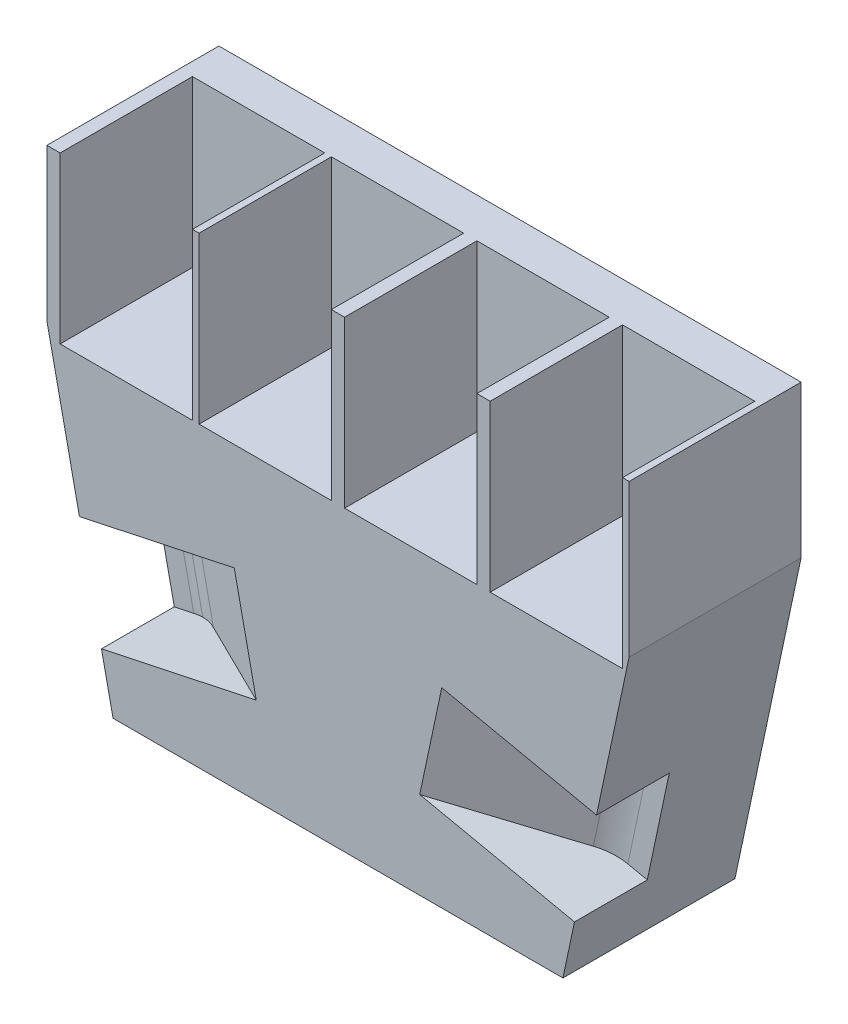
from build123d import *

# Parameters (mm, degrees)
EXTRUDE_1_DEPTH     = 26
SKETCH_3_W          = 40
SKETCH_3_H          = 36
CUT_EXTRUDE_4_DEPTH = 20
SKETCH_4_W          = 20
SKETCH_4_H          = 20
CUT_EXTRUDE_5_DEPTH = 25
CUT_EXTRUDE_3_DEPTH = 8
CUT_EXTRUDE_6_DEPTH = 8
CUT_EXTRUDE_7_DEPTH = 16
CUT_EXTRUDE_8_DEPTH = 16


with BuildPart() as part:
    # 草图1 → 凸台-拉伸1 (new body)
    with BuildSketch(Plane.XY):
        Polygon((-34, -24), (34, -24), (44, 23), (44, 46), (-44, 46), (-44, 23), align=None)
    extrude(amount=EXTRUDE_1_DEPTH)

    # 草图3 → 切除-拉伸4 (cut)
    with BuildSketch(Plane(origin=(0, 0, 0), x_dir=(-1, 0, 0), z_dir=(0, 0, -1))):
        with Locations((0, -6)):
            Rectangle(SKETCH_3_W, SKETCH_3_H)
    extrude(amount=-CUT_EXTRUDE_4_DEPTH, mode=Mode.SUBTRACT)

    # 草图4 → 切除-拉伸5 (cut)
    with BuildSketch(Plane(origin=(0, 46, 0), x_dir=(1, 0, 0), z_dir=(0, 1, 0))):
        with Locations((33, -16)):
            Rectangle(SKETCH_4_W, SKETCH_4_H)
        with Locations((11, -16)):
            Rectangle(SKETCH_4_W, SKETCH_4_H)
        with Locations((-11, -16)):
            Rectangle(SKETCH_4_W, SKETCH_4_H)
        with Locations((-32, -16)):
            Rectangle(SKETCH_4_W, SKETCH_4_H)
    extrude(amount=-CUT_EXTRUDE_5_DEPTH, mode=Mode.SUBTRACT)

    # Sketch 3D_5 → 切除-拉伸3 (cut, symmetric)
    with BuildSketch(Plane(origin=(-26.633413551, -5.666683734, 23.004025099), x_dir=(-0.691625335103945, -0.14715432661786076, 0.7071067811865475), z_dir=(-0.2081076444648591, 0.9781059289848354, 0))):
        with BuildLine():
            Line((0, 0), (5.656854249, 5.656854249))
            Line((5.656854249, 5.656854249), (11.313708499, 0))
            ThreePointArc((11.313708499, 0), (5.656854249, -13.656854249), (0, 0))
        make_face()
    extrude(amount=CUT_EXTRUDE_3_DEPTH, both=True, mode=Mode.SUBTRACT)

    # Sketch 3D_6 → 切除-拉伸6 (cut, symmetric)
    with BuildSketch(Plane(origin=(34.478414998, -7.335832978, 14.99907516), x_dir=(0.5895982688198705, -0.12544644017993214, 0.7978954016979886), z_dir=(-0.20810764446495697, -0.9781059289848145, -6.6559639472978385e-12))):
        with BuildLine():
            Line((0, 0), (6.376045072, -8.439700449))
            Line((6.376045072, -8.439700449), (17.547318622, 0))
            Line((17.547318622, 0), (11.17127355, 8.439700449))
            Line((11.17127355, 8.439700449), (6.348906145, 14.822863662))
            Line((6.348906145, 14.822863662), (1.560795809, 11.205530619))
            ThreePointArc((1.560795809, 11.205530619), (-1.540343474, 5.926016705), (0, 0))
        make_face()
    extrude(amount=CUT_EXTRUDE_6_DEPTH, both=True, mode=Mode.SUBTRACT)

    # 草图7 → 切除-拉伸7 (cut)
    with BuildSketch(Plane(origin=(-1.664861156, 7.824847432, 0), x_dir=(0.9781059289848355, 0.2081076444648587, 0), z_dir=(0.2081076444648587, -0.9781059289848355, 0))):
        with BuildLine():
            Line((-24.556702047, 20), (-31.200844281, 16.10051891))
            ThreePointArc((-31.200844281, 16.10051891), (-33.152072653, 15.280030806), (-35.250185053, 15))
            Line((-35.250185053, 15), (-43.250185053, 15))
            Line((-43.250185053, 15), (-43.250185053, 23))
            ThreePointArc((-43.250185053, 23), (-40.3181561, 29.189965223), (-33.671267687, 30.842641134))
            Line((-33.671267687, 30.842641134), (-10.087245225, 28.492198282))
            Line((-10.087245225, 28.492198282), (-24.556702047, 20))
        make_face()
    extrude(amount=CUT_EXTRUDE_7_DEPTH, mode=Mode.SUBTRACT)

    # 草图11 → 切除-拉伸8 (cut)
    with BuildSketch(Plane(origin=(-1.664861156, -7.824847432, 0), x_dir=(0.9781059289845859, -0.2081076444660318, -1.1269708570671002e-12), z_dir=(0.20810764446603178, 0.9781059289845858, 5.296763028184159e-12))):
        with BuildLine():
            Line((31.200844283, -16.100518909), (14.333584528, -26))
            Line((14.333584528, -26), (32.666556858, -30.571318601))
            ThreePointArc((32.666556858, -30.571318601), (42.196349228, -26.968728166), (40.460809076, -16.92962956))
            Line((40.460809076, -16.92962956), (38.250185053, -14.99907516))
            Line((38.250185053, -14.99907516), (35.250185053, -15))
            ThreePointArc((35.250185053, -15), (33.152072655, -15.280030806), (31.200844283, -16.100518909))
        make_face()
    extrude(amount=CUT_EXTRUDE_8_DEPTH, mode=Mode.SUBTRACT)


solid = part.part
